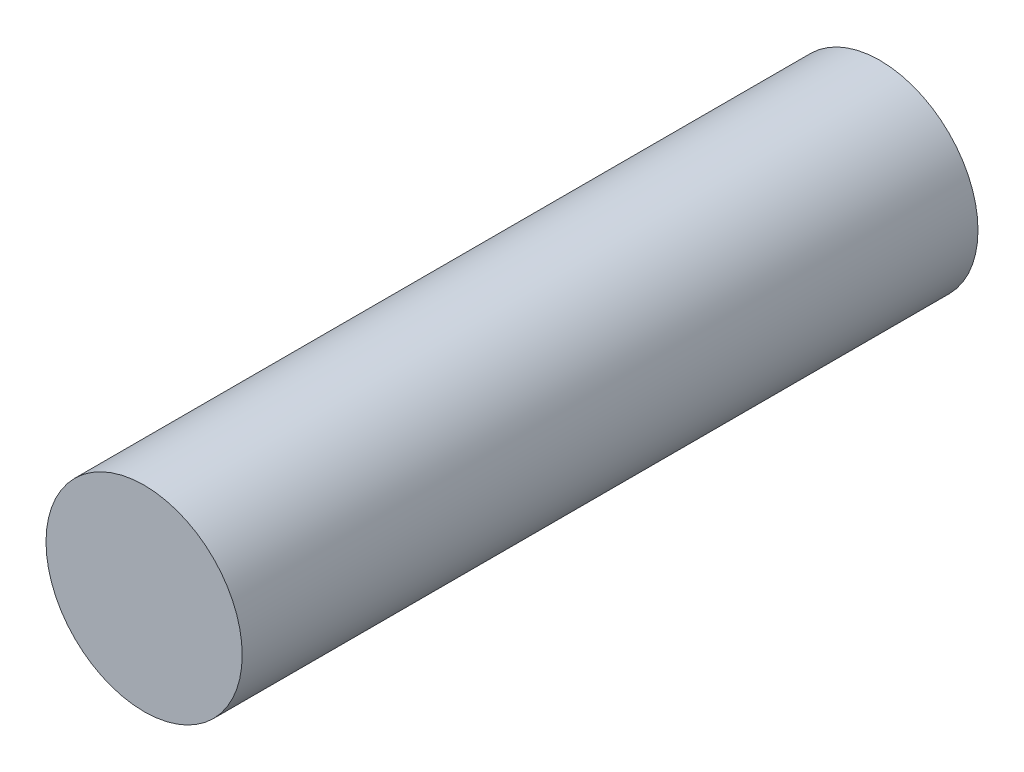
from build123d import *

# Parameters (mm, degrees)
SKETCH1_R           = 4
BOSS_EXTRUDE1_DEPTH = 60
SKETCH3_R           = 4
CUT_EXTRUDE1_DEPTH  = 30


with BuildPart() as part:
    # Sketch1 → Boss-Extrude1 (new body)
    with BuildSketch(Plane.XY):
        Circle(SKETCH1_R)
    extrude(amount=BOSS_EXTRUDE1_DEPTH)

    # Sketch3 → Cut-Extrude1 (cut)
    with BuildSketch(Plane.XY.offset(60)):
        Circle(SKETCH3_R)
    extrude(amount=-CUT_EXTRUDE1_DEPTH, mode=Mode.SUBTRACT)


solid = part.part
